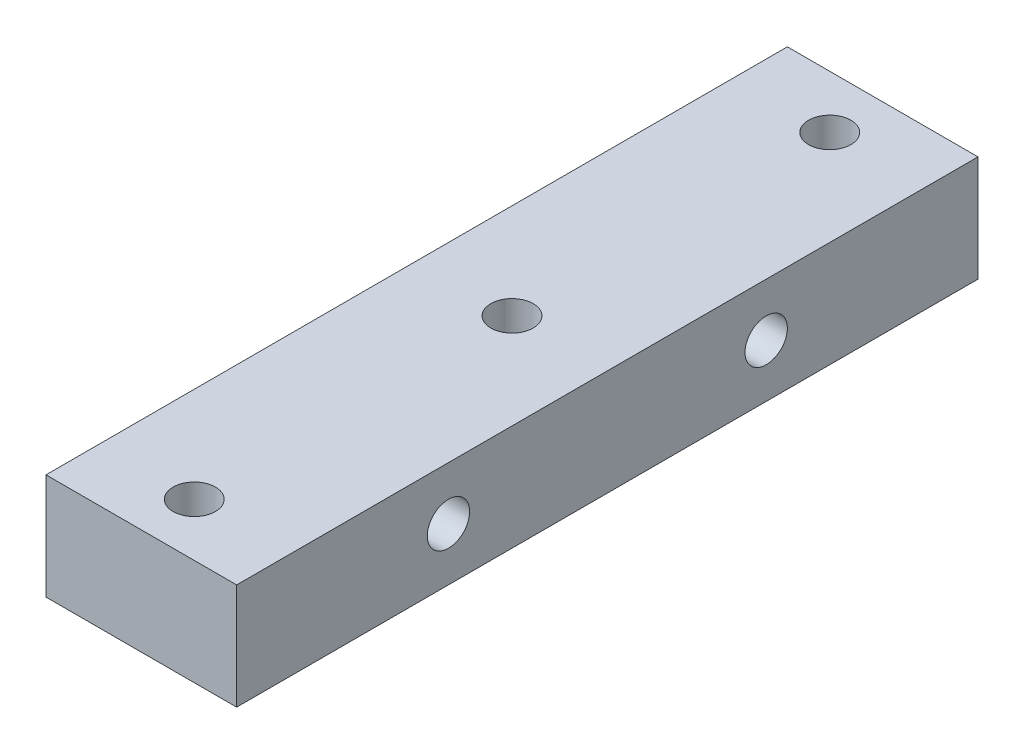
from build123d import *

# Parameters (mm, degrees)
SKETCH_1_W          = 18
SKETCH_1_H          = 10
EXTRUDE_1_DEPTH     = 70
SKETCH_2_R          = 2
CUT_EXTRUDE_1_DEPTH = 11
SKETCH_3_R          = 2
CUT_EXTRUDE_2_DEPTH = 19


with BuildPart() as part:
    # 草图1 → 凸台-拉伸1 (new body)
    with BuildSketch(Plane.XY):
        Rectangle(SKETCH_1_W, SKETCH_1_H)
    extrude(amount=EXTRUDE_1_DEPTH)

    # 草图2 → 切除-拉伸1 (cut, through all)
    with BuildSketch(Plane(origin=(0, 5, 0), x_dir=(1, 0, 0), z_dir=(0, 1, 0))):
        with Locations((0, -5)):
            Circle(SKETCH_2_R)
        with Locations((0, -35)):
            Circle(SKETCH_2_R)
        with Locations((0, -65)):
            Circle(SKETCH_2_R)
    extrude(amount=-CUT_EXTRUDE_1_DEPTH, mode=Mode.SUBTRACT)

    # 草图3 → 切除-拉伸2 (cut, through all)
    with BuildSketch(Plane(origin=(9, 0, 0), x_dir=(0, 0, -1), z_dir=(1, 0, 0))):
        with Locations((-50, 0)):
            Circle(SKETCH_3_R)
        with Locations((-20, 0)):
            Circle(SKETCH_3_R)
    extrude(amount=-CUT_EXTRUDE_2_DEPTH, mode=Mode.SUBTRACT)


solid = part.part
